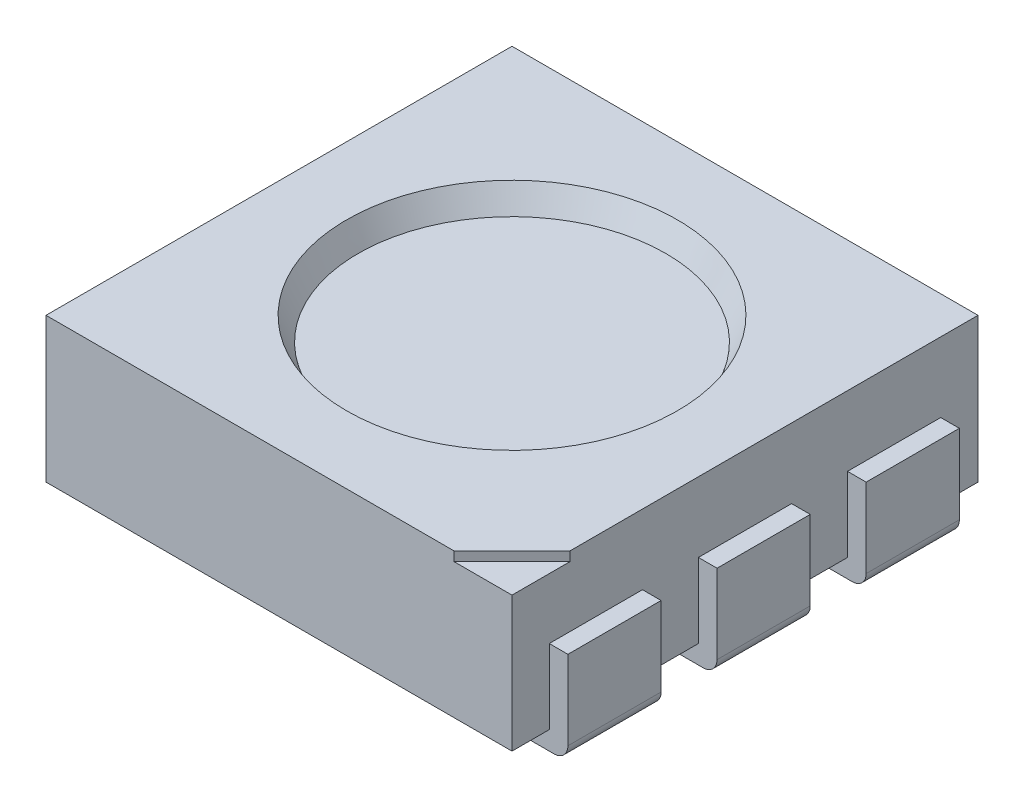
from build123d import *

# Parameters (mm, degrees)
SKETCH1_W            = 5
SKETCH1_H            = 5
BOSS_EXTRUDE1_DEPTH  = 1.55
SKETCH6_W            = 1
SKETCH6_H            = 0.8
BOSS_EXTRUDE3_DEPTH  = 0.2
SKETCH7_W            = 1
SKETCH7_H            = 1
BOSS_EXTRUDE5_DEPTH  = 0.2
FILLET1_R            = 0.15
FILLET1_OF_MIRROR1_R = 0.15
CUT_EXTRUDE2_DEPTH   = 0.1


with BuildPart() as part:
    # Sketch1 → Boss-Extrude1 (new body)
    with BuildSketch(Plane(origin=(0, 0, 0), x_dir=(1, 0, 0), z_dir=(0, 1, 0))):
        Rectangle(SKETCH1_W, SKETCH1_H)
    extrude(amount=BOSS_EXTRUDE1_DEPTH)

    # Sketch5 → CSK SLOT for M2 Flat Head Machine Screw1 (revolve, cut)
    with BuildSketch(Plane(origin=(0, 1.55, 0), x_dir=(0, 0, 1), z_dir=(1, 0, 0))):
        Polygon((0, 0), (0, 0.25), (1.65, 0.25), (1.775, 0), align=None)
    revolve(axis=Axis((0, 7.9, 0), (0, -1, 0)), mode=Mode.SUBTRACT)

    # Sketch6 → Boss-Extrude3 (add)
    with BuildSketch(Plane.ZY.offset(2.5)):
        with Locations((0, 0.4)):
            Rectangle(SKETCH6_W, SKETCH6_H)
        with Locations((1.6, 0.4)):
            Rectangle(SKETCH6_W, SKETCH6_H)
        with Locations((-1.6, 0.4)):
            Rectangle(SKETCH6_W, SKETCH6_H)
    boss_extrude3 = extrude(amount=BOSS_EXTRUDE3_DEPTH)

    # Sketch7 → Boss-Extrude5 (add)
    with BuildSketch(Plane.XZ):
        with Locations((-2.2, -1.6)):
            Rectangle(SKETCH7_W, SKETCH7_H)
        with Locations((-2.2, 0)):
            Rectangle(SKETCH7_W, SKETCH7_H)
        with Locations((-2.2, 1.6)):
            Rectangle(SKETCH7_W, SKETCH7_H)
    boss_extrude5 = extrude(amount=BOSS_EXTRUDE5_DEPTH)

    # Fillet1
    fillet1_edges = [part.edges().sort_by_distance(p)[0] for p in [
        (-2.7, -0.2, -1.6),
        (-2.7, -0.2, 0),
        (-2.7, -0.2, 1.6),
    ]]
    fillet(fillet1_edges, radius=FILLET1_R)

    # Mirror1: Boss-Extrude3, Boss-Extrude5 across plane
    add(boss_extrude3.mirror(Plane.ZY))
    add(boss_extrude5.mirror(Plane.ZY))

    # Fillet1 of Mirror1
    fillet1_of_mirror1_edges = [part.edges().sort_by_distance(p)[0] for p in [
        (2.7, -0.2, -1.6),
        (2.7, -0.2, 0),
        (2.7, -0.2, 1.6),
    ]]
    fillet(fillet1_of_mirror1_edges, radius=FILLET1_OF_MIRROR1_R)

    # Sketch9 → Cut-Extrude2 (cut)
    with BuildSketch(Plane(origin=(0, 1.55, 0), x_dir=(1, 0, 0), z_dir=(0, 1, 0))):
        Polygon((1.878160882, -2.5), (2.5, -1.878160882), (2.5, -2.5), align=None)
    extrude(amount=-CUT_EXTRUDE2_DEPTH, mode=Mode.SUBTRACT)


solid = part.part
